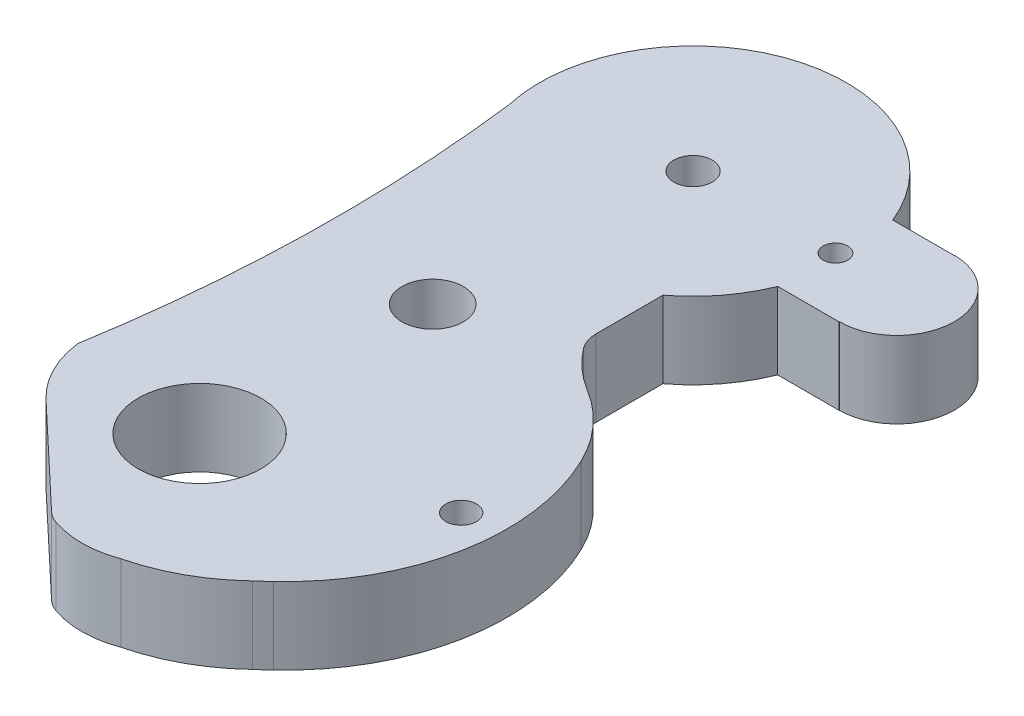
from build123d import *

# Parameters (mm, degrees)
SKETCH1_R           = 2
SKETCH1_R_2         = 4
SKETCH1_R_3         = 1.25
SKETCH1_R_4         = 0.801632387
SKETCH1_R_5         = 1
BOSS_EXTRUDE1_DEPTH = 5
FILLET1_R           = 10
FILLET2_R           = 2
FILLET3_R           = 2


with BuildPart() as part:
    # Sketch1 → Boss-Extrude1 (new body)
    with BuildSketch(Plane(origin=(0, 0, 0), x_dir=(1, 0, 0), z_dir=(0, 1, 0))):
        with BuildLine():
            Line((10.245447832, 19.748535419), (14.245447832, 19.748535419))
            Line((14.245447832, 19.748535419), (14.245447832, 19.765232538))
            ThreePointArc((14.245447832, 19.765232538), (17.995447832, 16.015232538), (14.245447832, 12.265232538))
            Line((14.245447832, 12.265232538), (14.245447832, 12.251464581))
            Line((14.245447832, 12.251464581), (10.245447832, 12.251464581))
            ThreePointArc((10.245447832, 12.251464581), (8.910242614, 9.915125816), (7.000398069, 8.019408112))
            Line((7.000398069, 8.019408112), (7.000398069, 3.019408112))
            ThreePointArc((7.000398069, 3.019408112), (8.876398613, 0.90896847), (11.319846515, -0.506268567))
            ThreePointArc((11.319846515, -0.506268567), (15.105800834, -10.846250302), (10.471403603, -20.834795477))
            ThreePointArc((10.471403603, -20.834795477), (10.121274527, -21.168091922), (9.758861069, -21.487987805))
            ThreePointArc((9.758861069, -21.487987805), (7.187603365, -23.373618777), (4.217131367, -24.532612502))
            ThreePointArc((4.217131367, -24.532612502), (1.88896648, -24.924600666), (-0.415858892, -24.412949939))
            Line((-0.415858892, -24.412949939), (-7.21726234, -17.990260503))
            ThreePointArc((-7.21726234, -17.990260503), (-8.645604673, -16.078135797), (-9.343313072, -13.79568411))
            ThreePointArc((-9.343313072, -13.79568411), (-8.067302671, -0.037990819), (-8.771466645, 13.760794646))
            ThreePointArc((-8.771466645, 13.760794646), (-2.028677736, 25.538358263), (10.245447832, 19.748535419))
        make_face()
        Circle(SKETCH1_R, mode=Mode.SUBTRACT)
        with Locations((-0.296635989, -14.897704258)):
            Circle(SKETCH1_R_2, mode=Mode.SUBTRACT)
        with Locations((0.974607405, 16)):
            Circle(SKETCH1_R_3, mode=Mode.SUBTRACT)
        with Locations((10.245447832, 16.015232538)):
            Circle(SKETCH1_R_4, mode=Mode.SUBTRACT)
        with Locations((12.706975529, -10.846250302)):
            Circle(SKETCH1_R_5, mode=Mode.SUBTRACT)
    extrude(amount=BOSS_EXTRUDE1_DEPTH)

    # Fillet1
    fillet1_edges = [part.edges().sort_by_distance(p)[0] for p in [
        (11.319846515, 2.5, 0.506268567),
    ]]
    fillet(fillet1_edges, radius=FILLET1_R)

    # Fillet2
    fillet2_edges = [part.edges().sort_by_distance(p)[0] for p in [
        (7.000398069, 2.5, -3.019408112),
    ]]
    fillet(fillet2_edges, radius=FILLET2_R)

    # Fillet3
    fillet3_edges = [part.edges().sort_by_distance(p)[0] for p in [
        (-0.415858892, 2.5, 24.412949939),
    ]]
    fillet(fillet3_edges, radius=FILLET3_R)


solid = part.part
